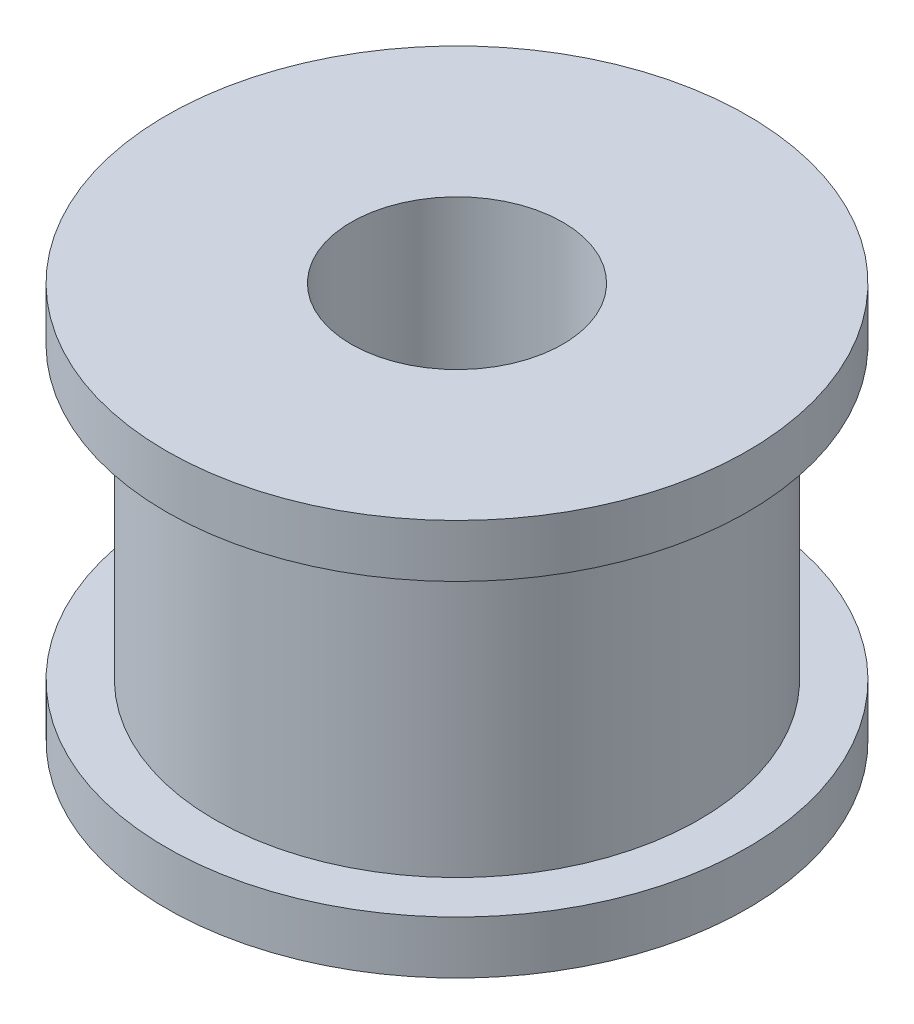
from build123d import *

# Parameters (mm, degrees)
SKETCH_1_R          = 9.17
EXTRUDE_2_DEPTH     = 11
SKETCH_3_R          = 11
EXTRUDE_3_DEPTH     = 2
SKETCH_4_R          = 11
EXTRUDE_4_DEPTH     = 2
SKETCH_5_R          = 4.005
CUT_EXTRUDE_2_DEPTH = 16


with BuildPart() as part:
    # 草图1 → 凸台-拉伸2 (new body)
    with BuildSketch(Plane(origin=(0, 0, 0), x_dir=(1, 0, 0), z_dir=(0, 1, 0))):
        Circle(SKETCH_1_R)
    extrude(amount=EXTRUDE_2_DEPTH)

    # 草图3 → 凸台-拉伸3 (add)
    with BuildSketch(Plane(origin=(0, 11, 0), x_dir=(1, 0, 0), z_dir=(0, 1, 0))):
        Circle(SKETCH_3_R)
    extrude(amount=EXTRUDE_3_DEPTH)

    # 草图4 → 凸台-拉伸4 (add)
    with BuildSketch(Plane.XZ):
        Circle(SKETCH_4_R)
    extrude(amount=EXTRUDE_4_DEPTH)

    # 草图5 → 切除-拉伸2 (cut, through all)
    with BuildSketch(Plane.XZ.offset(2)):
        Circle(SKETCH_5_R)
    extrude(amount=-CUT_EXTRUDE_2_DEPTH, mode=Mode.SUBTRACT)


solid = part.part
